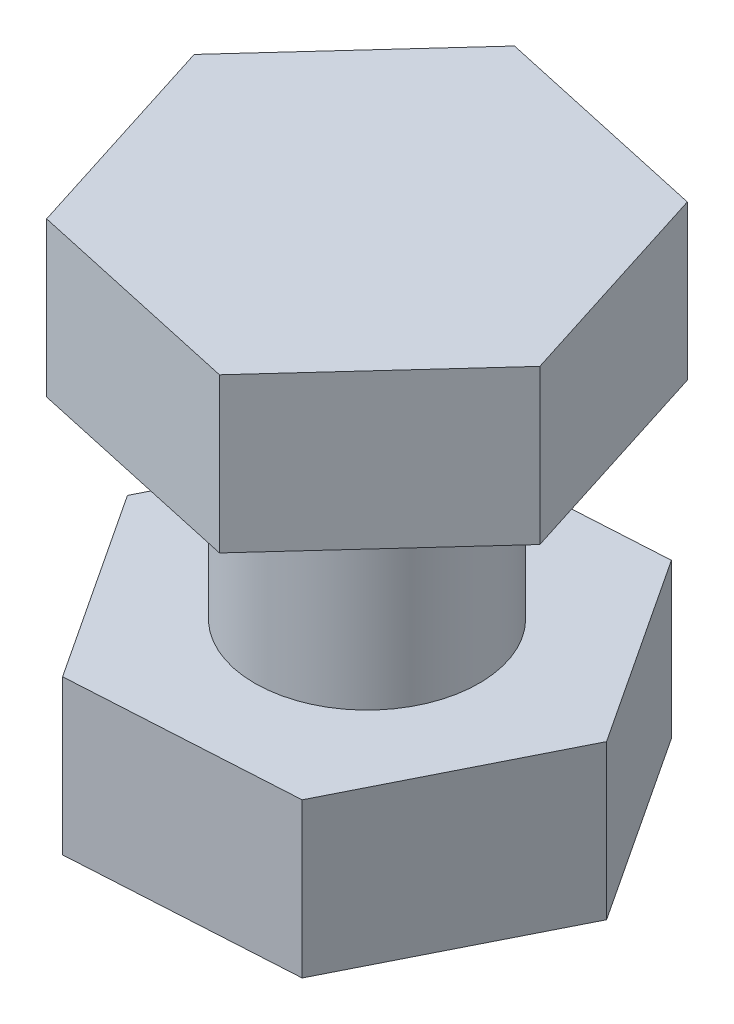
from build123d import *

# Parameters (mm, degrees)
SKETCH1_R           = 3.175
BOSS_EXTRUDE1_DEPTH = 10
BOSS_EXTRUDE2_DEPTH = 4.365625
BOSS_EXTRUDE3_DEPTH = 4.365625


with BuildPart() as part:
    # Sketch1 → Boss-Extrude1 (new body)
    with BuildSketch(Plane(origin=(0, 0, 0), x_dir=(1, 0, 0), z_dir=(0, 1, 0))):
        Circle(SKETCH1_R)
    extrude(amount=BOSS_EXTRUDE1_DEPTH)

    # Sketch2 → Boss-Extrude2 (add)
    with BuildSketch(Plane.XZ):
        Polygon((6.404947556, -0.373093671), (3.525582375, 5.360300458), (-2.879365181, 5.733394129), (-6.404947556, 0.373093671), (-3.525582375, -5.360300458), (2.879365181, -5.733394129), align=None)
    extrude(amount=BOSS_EXTRUDE2_DEPTH)

    # Sketch3 → Boss-Extrude3 (add)
    with BuildSketch(Plane(origin=(0, 10, 0), x_dir=(1, 0, 0), z_dir=(0, 1, 0))):
        Polygon((-6.266509765, 1.376011426), (-4.324915734, -4.738950937), (1.941594032, -6.114962363), (6.266509765, -1.376011426), (4.324915734, 4.738950937), (-1.941594032, 6.114962363), align=None)
    extrude(amount=-BOSS_EXTRUDE3_DEPTH)


solid = part.part
